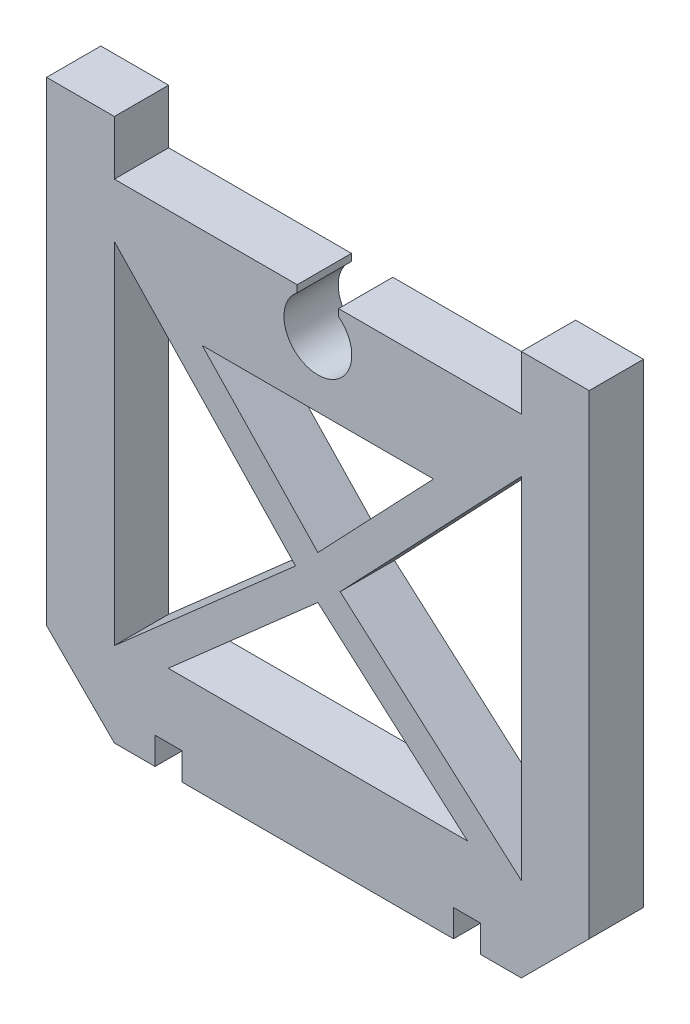
from build123d import *

# Parameters (mm, degrees)
EXTRUDE_3_DEPTH = 4


with BuildPart() as part:
    # ｽｹｯﾁ1 → ﾎﾞｽ - 押し出し3 (new body)
    with BuildSketch(Plane.XY):
        with BuildLine():
            Line((15, 6.5), (15, 2.5))
            Line((15, 2.5), (1.523471671, 2.5))
            Line((1.523471671, 2.5), (1.523471671, 1.982179121))
            ThreePointArc((1.523471671, 1.982179121), (2.242618913, 1.104835015), (2.5, 0))
            ThreePointArc((2.5, 0), (-1.104835015, -2.242618913), (-1.523471671, 1.982179121))
            Line((-1.523471671, 1.982179121), (-1.523471671, 2.5))
            Line((-1.523471671, 2.5), (-15, 2.5))
            Line((-15, 2.5), (-15, 6.5))
            Line((-15, 6.5), (-20, 6.5))
            Line((-20, 6.5), (-20, -28.5))
            Line((-20, -28.5), (-15, -33.5))
            Line((-15, -33.5), (-12, -33.5))
            Line((-12, -33.5), (-12, -31.5))
            Line((-12, -31.5), (-10, -31.5))
            Line((-10, -31.5), (-10, -33.5))
            Line((-10, -33.5), (0, -33.5))
            Line((0, -33.5), (10, -33.5))
            Line((10, -33.5), (10, -31.5))
            Line((10, -31.5), (12, -31.5))
            Line((12, -31.5), (12, -33.5))
            Line((12, -33.5), (15, -33.5))
            Line((15, -33.5), (20, -28.5))
            Line((20, -28.5), (20, 6.5))
            Line((20, 6.5), (15, 6.5))
        make_face()
        Polygon((-15, -27.27974657), (-15, -1.481890402), (-1.643206603, -15.516883287), align=None, mode=Mode.SUBTRACT)
        Polygon((-11.029061917, -26.739072938), (0, -17.026161792), (11.029061917, -26.739072938), align=None, mode=Mode.SUBTRACT)
        Polygon((15, -27.27974657), (1.643206603, -15.516883287), (15, -1.481890402), align=None, mode=Mode.SUBTRACT)
        Polygon((-8.526128996, -4.880410376), (8.526128996, -4.880410376), (0, -13.839458872), align=None, mode=Mode.SUBTRACT)
    extrude(amount=EXTRUDE_3_DEPTH)


solid = part.part
